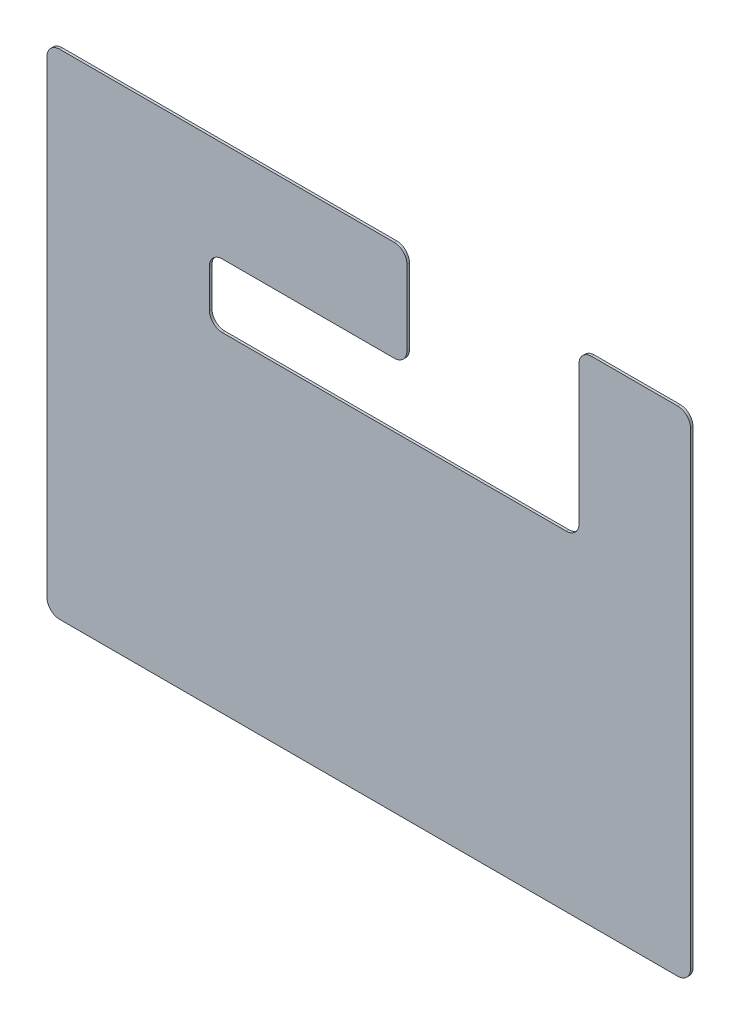
from build123d import *

# Parameters (mm, degrees)
SKETCH1_W           = 1010
SKETCH1_H           = 775
BOSS_EXTRUDE1_DEPTH = 4
FILLET1_R           = 20
SKETCH2_W           = 500
SKETCH2_H           = 100
SKETCH2_W_2         = 80
CUT_EXTRUDE1_DEPTH  = 10
FILLET2_R           = 20


with BuildPart() as part:
    # Sketch1 → Boss-Extrude1 (new body)
    with BuildSketch(Plane.XY):
        Rectangle(SKETCH1_W, SKETCH1_H)
    extrude(amount=BOSS_EXTRUDE1_DEPTH)

    # Fillet1
    fillet1_edges = [part.edges().sort_by_distance(p)[0] for p in [
        (505, -387.5, 2),
        (-505, -387.5, 2),
        (-505, 387.5, 2),
        (505, 387.5, 2),
    ]]
    fillet(fillet1_edges, radius=FILLET1_R)

    # Sketch2 → Cut-Extrude1 (cut)
    with BuildSketch(Plane.XY.offset(4)):
        Polygon((60, 230), (250, 230), (330, 230), (330, 387.5), (60, 387.5), align=None)
        with Locations((0, 180)):
            Rectangle(SKETCH2_W, SKETCH2_H)
        with Locations((290, 180)):
            Rectangle(SKETCH2_W_2, SKETCH2_H)
    extrude(amount=-CUT_EXTRUDE1_DEPTH, mode=Mode.SUBTRACT)

    # Fillet2
    fillet2_edges = [part.edges().sort_by_distance(p)[0] for p in [
        (60, 387.5, 2),
        (330, 387.5, 2),
        (330, 130, 2),
        (-250, 130, 2),
        (-250, 230, 2),
        (60, 230, 2),
    ]]
    fillet(fillet2_edges, radius=FILLET2_R)


solid = part.part
